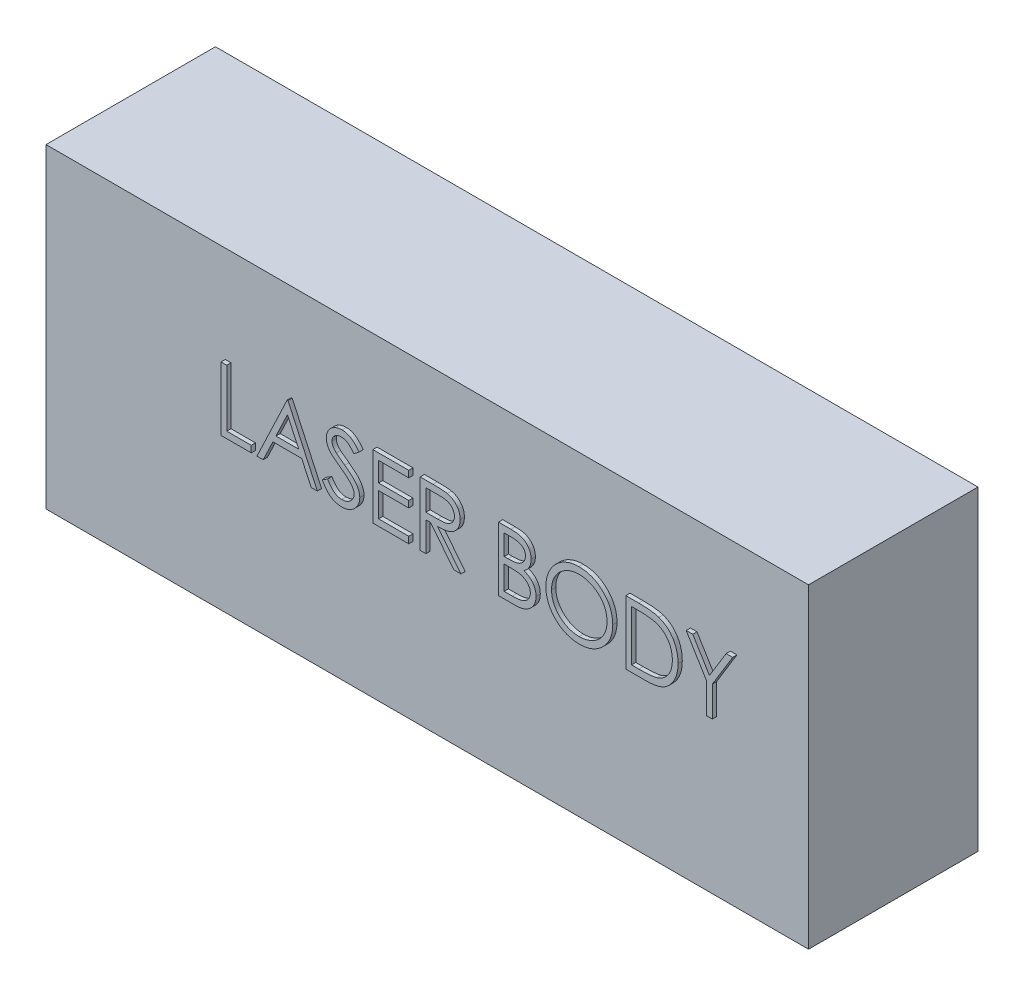
from build123d import *

# Parameters (mm, degrees)
SKETCH1_W                = 3600
SKETCH1_H                = 1490
BOSS_EXTRUDE1_DEPTH      = 800
BOSS_EXTRUDE2_DEPTH      = 20
BOSS_EXTRUDE2_DEPTH_BACK = 1


with BuildPart() as part:
    # Sketch1 → Boss-Extrude1 (new body)
    with BuildSketch(Plane.XY):
        with Locations((-1800, -745)):
            Rectangle(SKETCH1_W, SKETCH1_H)
    extrude(amount=BOSS_EXTRUDE1_DEPTH)

    # Sketch2 → Boss-Extrude2 (add, two sides)
    with BuildSketch(Plane.XY.offset(800)) as boss_extrude2_sk:
        Polygon((-2753.573068103, -455.44321141), (-2726.605119385, -455.44321141), (-2726.605119385, -725.122698589), (-2611.028196308, -725.122698589), (-2611.028196308, -755.94321141), (-2753.573068103, -755.94321141), align=None)
        Polygon((-2437.662811693, -455.44321141), (-2298.970504, -755.94321141), (-2328.286108968, -755.94321141), (-2372.710988776, -659.629108846), (-2508.93524759, -659.629108846), (-2554.624249994, -755.94321141), (-2584.06024759, -755.94321141), (-2441.515375795, -455.44321141), align=None)
        Polygon((-2439.890075314, -514.014225032), (-2494.307543263, -628.808596025), (-2386.917318904, -628.808596025), align=None, mode=Mode.SUBTRACT)
        with BuildLine():
            Line((-2275.855119385, -697.974160929), (-2250.452274834, -682.744493461))
            add(Edge.make_bspline(
                [(-2250.452274834, -682.744493461), (-2248.089637607, -686.69944994), (-2243.562915856, -694.27699393), (-2236.011663448, -704.516148544), (-2228.187252076, -713.218813717), (-2220.031739295, -720.33436245), (-2211.594905749, -725.936445441), (-2202.82167485, -729.90323705), (-2193.741611387, -732.377294364), (-2187.562144714, -732.677801795), (-2184.477114577, -732.827826794)],
                knots=[0, 0, 0, 0, 0.013814497, 0.026468043, 0.038101516, 0.04885528, 0.058856205, 0.068366651, 0.077638056, 0.086881278, 0.086881278, 0.086881278, 0.086881278], degree=3))
            add(Edge.make_bspline(
                [(-2184.477114577, -732.827826794), (-2181.84242841, -732.754447055), (-2176.619156896, -732.608971548), (-2168.929598607, -731.2111484), (-2161.461589584, -729.063678475), (-2154.369047973, -725.988195641), (-2147.749838783, -722.267277081), (-2141.945321083, -717.772983841), (-2136.927304795, -712.741222465), (-2132.822550815, -707.127654545), (-2129.673307786, -701.090425071), (-2127.25281734, -694.893604106), (-2125.909576016, -688.439845601), (-2125.707231898, -684.094575862), (-2125.605119385, -681.901745064)],
                knots=[0, 0, 0, 0, 0.007896967, 0.015655756, 0.023370519, 0.031164024, 0.038794723, 0.046091152, 0.053114543, 0.06004967, 0.066862499, 0.073492298, 0.079950159, 0.086529205, 0.086529205, 0.086529205, 0.086529205], degree=3))
            add(Edge.make_bspline(
                [(-2125.605119385, -681.901745064), (-2125.731699489, -679.399794967), (-2125.989018344, -674.313696028), (-2128.163906848, -666.809811538), (-2131.585249327, -659.383806598), (-2134.741584879, -654.790340796), (-2136.380259609, -652.405551153)],
                knots=[0, 0, 0, 0, 0.007493655, 0.015233506, 0.023259506, 0.031925476, 0.031925476, 0.031925476, 0.031925476], degree=3))
            add(Edge.make_bspline(
                [(-2136.380259609, -652.405551153), (-2137.72569377, -650.684388156), (-2140.550264494, -647.071021736), (-2145.406130932, -641.692480804), (-2151.104135889, -636.144527977), (-2157.44928396, -630.215314659), (-2164.672710588, -624.180605257), (-2172.548172896, -617.752628823), (-2181.276741359, -611.175836279), (-2187.398312426, -606.76513458), (-2190.556942302, -604.489285128)],
                knots=[0, 0, 0, 0, 0.006552556, 0.013756272, 0.021716082, 0.030406062, 0.039801702, 0.049945629, 0.060901524, 0.072581005, 0.072581005, 0.072581005, 0.072581005], degree=3))
            add(Edge.make_bspline(
                [(-2190.556942302, -604.489285128), (-2193.718545402, -602.237373534), (-2199.763289777, -597.931890047), (-2208.216662347, -591.542033662), (-2215.775908385, -585.699981434), (-2222.407429661, -580.350736967), (-2228.108309333, -575.49357476), (-2232.923470765, -571.175137414), (-2236.730252595, -567.278634545), (-2238.847110306, -564.750885061), (-2239.797527237, -563.615987852)],
                knots=[0, 0, 0, 0, 0.011644214, 0.022262851, 0.031787194, 0.040304706, 0.047819849, 0.0542541, 0.059703114, 0.064142974, 0.064142974, 0.064142974, 0.064142974], degree=3))
            add(Edge.make_bspline(
                [(-2239.797527237, -563.615987852), (-2241.125955764, -561.847241688), (-2243.738488745, -558.368764979), (-2247.187027214, -552.931873619), (-2250.118118191, -547.36633326), (-2252.415855565, -541.657188317), (-2254.350750925, -535.884589423), (-2255.652167548, -529.973218185), (-2256.467071769, -523.949599657), (-2256.550523756, -519.895983389), (-2256.592298872, -517.866789134)],
                knots=[0, 0, 0, 0, 0.006634169, 0.013046984, 0.019293494, 0.025475277, 0.031490693, 0.037536753, 0.043607037, 0.049691631, 0.049691631, 0.049691631, 0.049691631], degree=3))
            add(Edge.make_bspline(
                [(-2256.592298872, -517.866789134), (-2256.480237357, -514.687518489), (-2256.258509563, -508.396931874), (-2254.383345152, -499.207570575), (-2251.423600997, -490.434136754), (-2247.27713991, -482.16348953), (-2241.931901467, -474.610981742), (-2235.746239953, -467.689738074), (-2228.378710921, -461.871321229), (-2220.295035695, -456.787543073), (-2211.446910035, -452.808414352), (-2202.175119614, -449.806764484), (-2192.464928145, -448.105998216), (-2185.888001872, -447.861926543), (-2182.550832526, -447.738083205)],
                knots=[0, 0, 0, 0, 0.009530048, 0.018856398, 0.02801277, 0.037246578, 0.046498029, 0.055701965, 0.064990356, 0.07456157, 0.084286209, 0.094014388, 0.103732877, 0.113743581, 0.113743581, 0.113743581, 0.113743581], degree=3))
            add(Edge.make_bspline(
                [(-2182.550832526, -447.738083205), (-2179.009731915, -447.860219421), (-2171.967613, -448.103109372), (-2161.609016064, -450.214983133), (-2151.635788841, -453.709426525), (-2143.613017105, -457.675052731), (-2137.334047156, -461.63576428), (-2132.545559678, -465.243466336), (-2127.693132832, -469.396814946), (-2122.737625553, -474.106873074), (-2117.763006078, -479.416858418), (-2112.695421107, -485.290404708), (-2107.523020314, -491.691617576), (-2104.195552894, -496.261321141), (-2102.489734769, -498.603968621)],
                knots=[0, 0, 0, 0, 0.010615224, 0.021110292, 0.031561766, 0.042249282, 0.047877235, 0.053812604, 0.060217786, 0.067030349, 0.074312113, 0.082036264, 0.090299839, 0.09899232, 0.09899232, 0.09899232, 0.09899232], degree=3))
            Line((-2102.489734769, -498.603968621), (-2126.869241981, -517.084237051))
            add(Edge.make_bspline(
                [(-2126.869241981, -517.084237051), (-2128.341342755, -515.187765202), (-2131.176264655, -511.535603832), (-2135.48023917, -506.420980878), (-2139.536873084, -501.748937421), (-2143.533557408, -497.690888571), (-2147.259210624, -494.024605409), (-2150.875259537, -490.885689145), (-2154.329665979, -488.243384451), (-2158.684075021, -485.423530232), (-2164.154696266, -482.628321855), (-2171.02194002, -480.263036723), (-2178.198418777, -478.841666407), (-2183.086234281, -478.653734774), (-2185.560648231, -478.558596025)],
                knots=[0, 0, 0, 0, 0.007201452, 0.013868313, 0.020052147, 0.025756522, 0.030950177, 0.035729628, 0.040111986, 0.043985655, 0.051281339, 0.058477254, 0.065714092, 0.073133883, 0.073133883, 0.073133883, 0.073133883], degree=3))
            add(Edge.make_bspline(
                [(-2185.560648231, -478.558596025), (-2188.66494394, -478.662629121), (-2194.651285783, -478.863247146), (-2203.150304626, -481.054320169), (-2210.799654478, -484.50421989), (-2217.372238992, -489.339263009), (-2222.844513735, -495.06773681), (-2226.802996695, -501.659749938), (-2229.185546537, -508.93892479), (-2229.476282833, -514.016658427), (-2229.624350154, -516.602666538)],
                knots=[0, 0, 0, 0, 0.009293851, 0.017922316, 0.026137514, 0.034325098, 0.042246347, 0.049751599, 0.057214, 0.064958765, 0.064958765, 0.064958765, 0.064958765], degree=3))
            add(Edge.make_bspline(
                [(-2229.624350154, -516.602666538), (-2229.590597424, -518.21261491), (-2229.523036773, -521.435144236), (-2228.580772, -526.196044892), (-2227.370243899, -530.944918462), (-2225.451969373, -535.660414503), (-2222.803679734, -540.425001616), (-2219.32602106, -545.320725083), (-2214.94616384, -550.390736071), (-2211.591123208, -553.688283448), (-2209.819762814, -555.429289134)],
                knots=[0, 0, 0, 0, 0.004821721, 0.009651326, 0.014513833, 0.019510489, 0.024872018, 0.030834188, 0.03749398, 0.044943015, 0.044943015, 0.044943015, 0.044943015], degree=3))
            add(Edge.make_bspline(
                [(-2209.819762814, -555.429289134), (-2209.161979269, -556.016296636), (-2207.599236133, -557.410892094), (-2204.742260224, -559.694029333), (-2200.969457118, -562.51038164), (-2196.379345274, -565.995092668), (-2190.88729036, -570.037372487), (-2184.492688469, -574.585535474), (-2177.266819721, -579.787229884), (-2172.139266656, -583.423927299), (-2169.428036052, -585.346857243)],
                knots=[0, 0, 0, 0, 0.00264453, 0.006282799, 0.010966134, 0.016769071, 0.023571521, 0.03142293, 0.040309993, 0.050281709, 0.050281709, 0.050281709, 0.050281709], degree=3))
            add(Edge.make_bspline(
                [(-2169.428036052, -585.346857243), (-2166.166674066, -587.720065399), (-2159.851498597, -592.315454072), (-2150.865897808, -599.2197146), (-2142.71858657, -605.972187302), (-2135.380960092, -612.529750426), (-2128.780528381, -618.842662411), (-2122.990518363, -624.986872608), (-2117.951933522, -630.918362491), (-2112.527546337, -638.522950775), (-2106.984796404, -647.862583868), (-2102.224746981, -659.305472634), (-2099.223323149, -670.792842437), (-2098.830825896, -678.513703683), (-2098.637170667, -682.323119262)],
                knots=[0, 0, 0, 0, 0.012100058, 0.023430085, 0.033989178, 0.043837302, 0.052947851, 0.061379633, 0.069156382, 0.076273053, 0.0893848, 0.101637079, 0.113360688, 0.124778486, 0.124778486, 0.124778486, 0.124778486], degree=3))
            add(Edge.make_bspline(
                [(-2098.637170667, -682.323119262), (-2098.693590669, -685.017176037), (-2098.805335034, -690.352972824), (-2100.089836346, -698.187872996), (-2101.971796169, -705.797466236), (-2104.808278684, -713.087691748), (-2108.270309843, -720.191920658), (-2112.663297695, -726.923798965), (-2117.755286056, -733.432319758), (-2123.596470729, -739.543930944), (-2129.988183199, -745.154368628), (-2136.743740412, -750.145163763), (-2143.87419956, -754.306515529), (-2151.340879035, -757.702237825), (-2159.145493944, -760.358101258), (-2167.285419385, -762.282406165), (-2175.774073134, -763.463432202), (-2181.54371448, -763.586015722), (-2184.477114577, -763.648339615)],
                knots=[0, 0, 0, 0, 0.008074388, 0.015991977, 0.023759168, 0.03155151, 0.039412375, 0.047427305, 0.055615996, 0.064174252, 0.072747737, 0.081103541, 0.089331961, 0.097467376, 0.105671981, 0.114023664, 0.122528404, 0.131324484, 0.131324484, 0.131324484, 0.131324484], degree=3))
            add(Edge.make_bspline(
                [(-2184.477114577, -763.648339615), (-2186.746777596, -763.604451024), (-2191.257519566, -763.517226572), (-2197.929433653, -762.746119496), (-2204.46656124, -761.655123888), (-2210.786873169, -759.92303588), (-2216.971799511, -757.821512565), (-2222.994440647, -755.233921438), (-2228.857715414, -752.133001713), (-2234.594482171, -748.587528885), (-2240.190150589, -744.461428244), (-2245.592236336, -739.655703764), (-2250.977984978, -734.302896836), (-2256.188431433, -728.257647039), (-2261.328968537, -721.61762021), (-2266.298243413, -714.32069175), (-2271.199116603, -706.40660752), (-2274.27413034, -700.837476589), (-2275.855119385, -697.974160929)],
                knots=[0, 0, 0, 0, 0.006806444, 0.013527168, 0.020128209, 0.026669695, 0.033161136, 0.039713692, 0.046310615, 0.053042382, 0.059929009, 0.067137753, 0.074714363, 0.08269327, 0.091061424, 0.099894092, 0.109165497, 0.118976573, 0.118976573, 0.118976573, 0.118976573], degree=3))
        make_face()
        Polygon((-2036.996145026, -455.44321141), (-1867.483324513, -455.44321141), (-1867.483324513, -486.26372423), (-2010.028196308, -486.26372423), (-2010.028196308, -578.725262692), (-1867.483324513, -578.725262692), (-1867.483324513, -609.545775512), (-2010.028196308, -609.545775512), (-2010.028196308, -725.122698589), (-1867.483324513, -725.122698589), (-1867.483324513, -755.94321141), (-2036.996145026, -755.94321141), align=None)
        with BuildLine():
            Line((-1813.547427077, -455.44321141), (-1753.411309289, -455.44321141))
            add(Edge.make_bspline(
                [(-1753.411309289, -455.44321141), (-1749.398249541, -455.456569578), (-1741.692730285, -455.482218741), (-1730.653796644, -455.625236385), (-1720.623355887, -456.035148925), (-1711.60665254, -456.387900164), (-1703.60385202, -457.03113684), (-1696.590414629, -457.645929543), (-1690.598642315, -458.450725276), (-1686.971534224, -459.198148019), (-1685.329278039, -459.536560769)],
                knots=[0, 0, 0, 0, 0.012039413, 0.023117007, 0.033116121, 0.042155394, 0.050184102, 0.0571982, 0.063276538, 0.068305723, 0.068305723, 0.068305723, 0.068305723], degree=3))
            add(Edge.make_bspline(
                [(-1685.329278039, -459.536560769), (-1683.130766452, -460.079758767), (-1678.780643499, -461.154566874), (-1672.517359257, -463.426312602), (-1666.549058015, -466.055226088), (-1660.90053167, -469.142968361), (-1655.600073026, -472.712460159), (-1650.593029485, -476.702080385), (-1645.856680415, -481.089999052), (-1641.582571881, -485.986847586), (-1637.552519014, -491.124239346), (-1634.153552653, -496.679519041), (-1631.223550608, -502.488744475), (-1628.890767649, -508.610995628), (-1627.012387355, -514.986899184), (-1625.687934517, -521.674208731), (-1624.893653979, -528.642458164), (-1624.812788953, -533.395330047), (-1624.771786052, -535.805290737)],
                knots=[0, 0, 0, 0, 0.006789653, 0.013434465, 0.019955979, 0.026340762, 0.032718448, 0.039101812, 0.045532683, 0.052056419, 0.0585821, 0.065096943, 0.071557889, 0.078075235, 0.084723318, 0.091476046, 0.098502531, 0.105730101, 0.105730101, 0.105730101, 0.105730101], degree=3))
            add(Edge.make_bspline(
                [(-1624.771786052, -535.805290737), (-1624.897910032, -539.809247576), (-1625.144010585, -547.622004418), (-1627.438551629, -558.960374379), (-1631.197078537, -569.537056965), (-1636.37626378, -579.338734877), (-1642.97176448, -588.174348858), (-1650.898507259, -595.935015092), (-1660.160914188, -602.429241873), (-1668.783488314, -606.932689819), (-1676.400236031, -609.816880974), (-1682.6706676, -611.846231213), (-1689.510646668, -613.414151375), (-1696.854637825, -614.818785545), (-1704.733203104, -615.879266737), (-1713.127459343, -616.655981491), (-1722.043393218, -617.141421957), (-1728.168361887, -617.213714092), (-1731.319262013, -617.250903718)],
                knots=[0, 0, 0, 0, 0.012000826, 0.02341672, 0.034535943, 0.045576675, 0.05654447, 0.067484477, 0.07870879, 0.090366533, 0.096559737, 0.103127759, 0.11012142, 0.117594739, 0.125554549, 0.133958351, 0.142880411, 0.152332958, 0.152332958, 0.152332958, 0.152332958], degree=3))
            Line((-1731.319262013, -617.250903718), (-1620.919221949, -755.94321141))
            Line((-1620.919221949, -755.94321141), (-1654.267979962, -755.94321141))
            Line((-1654.267979962, -755.94321141), (-1764.668020026, -617.250903718))
            Line((-1764.668020026, -617.250903718), (-1786.579478359, -617.250903718))
            Line((-1786.579478359, -617.250903718), (-1786.579478359, -755.94321141))
            Line((-1786.579478359, -755.94321141), (-1813.547427077, -755.94321141))
            Line((-1813.547427077, -755.94321141), (-1813.547427077, -455.44321141))
        make_face()
        with BuildLine():
            Line((-1786.579478359, -486.26372423), (-1786.579478359, -586.430390897))
            Line((-1786.579478359, -586.430390897), (-1731.560047269, -586.851765096))
            add(Edge.make_bspline(
                [(-1731.560047269, -586.851765096), (-1728.991198213, -586.852901557), (-1724.012037095, -586.855104343), (-1716.808565731, -586.512210125), (-1710.101396141, -586.122133802), (-1703.916182991, -585.525482849), (-1698.250163167, -584.75654012), (-1693.106168689, -583.794683902), (-1688.475802662, -582.674071094), (-1683.075513863, -580.939617221), (-1677.045205956, -578.191671939), (-1670.491604901, -574.193691265), (-1664.910689903, -569.165114034), (-1660.195599153, -563.414964451), (-1656.406772251, -557.092766515), (-1653.735580157, -550.274303958), (-1652.040550469, -543.131711044), (-1651.84062821, -538.22256207), (-1651.739734769, -535.745094423)],
                knots=[0, 0, 0, 0, 0.007705363, 0.014935189, 0.021630253, 0.027859626, 0.033571936, 0.038778482, 0.043552623, 0.04785487, 0.05577612, 0.063375651, 0.070794221, 0.078193472, 0.085616193, 0.092803794, 0.100090532, 0.107514473, 0.107514473, 0.107514473, 0.107514473], degree=3))
            add(Edge.make_bspline(
                [(-1651.739734769, -535.745094423), (-1651.842945452, -533.328510021), (-1652.047471363, -528.539721529), (-1653.71728706, -521.528978374), (-1656.541075374, -514.912230227), (-1660.346456087, -508.71639373), (-1664.982669249, -503.092258409), (-1670.418955739, -498.280209982), (-1676.506673208, -494.309363086), (-1682.196528952, -491.771908416), (-1687.282209196, -490.216189588), (-1691.697812866, -489.121411095), (-1696.68709831, -488.241850262), (-1702.274291256, -487.537129607), (-1708.435539842, -486.931412251), (-1715.201997172, -486.523438112), (-1722.528769306, -486.281847779), (-1727.606955827, -486.269906006), (-1730.235728359, -486.26372423)],
                knots=[0, 0, 0, 0, 0.007243845, 0.014354658, 0.021476419, 0.028744485, 0.036097312, 0.043260926, 0.050440456, 0.057823774, 0.061860071, 0.066386017, 0.071463247, 0.077048219, 0.083277593, 0.090032735, 0.097380631, 0.105266578, 0.105266578, 0.105266578, 0.105266578], degree=3))
            Line((-1730.235728359, -486.26372423), (-1786.579478359, -486.26372423))
        make_face(mode=Mode.SUBTRACT)
        with BuildLine():
            Line((-1443.701273231, -455.44321141), (-1385.070063295, -455.44321141))
            add(Edge.make_bspline(
                [(-1385.070063295, -455.44321141), (-1382.199989668, -455.458300837), (-1376.63707268, -455.487547903), (-1368.547660603, -455.941142448), (-1360.970869861, -456.559628962), (-1353.904503121, -457.540984059), (-1347.351825673, -458.72510664), (-1341.293089961, -460.15907685), (-1335.747562314, -461.87850468), (-1329.126883088, -464.612735397), (-1321.578266347, -468.675767423), (-1313.404804345, -474.67963423), (-1306.415668937, -482.023207135), (-1300.389672271, -490.306932265), (-1295.598747573, -499.419446383), (-1292.132755046, -509.143556734), (-1289.93842889, -519.353837718), (-1289.712759038, -526.363487705), (-1289.598709128, -529.906051955)],
                knots=[0, 0, 0, 0, 0.008608915, 0.016686219, 0.024299804, 0.031408323, 0.038079259, 0.044269829, 0.050076512, 0.055475755, 0.065737594, 0.075718208, 0.085765043, 0.09602388, 0.106363637, 0.116531292, 0.126920346, 0.137535569, 0.137535569, 0.137535569, 0.137535569], degree=3))
            add(Edge.make_bspline(
                [(-1289.598709128, -529.906051955), (-1289.69256974, -533.224649949), (-1289.877014695, -539.746007968), (-1291.640757317, -549.284230779), (-1294.401980422, -558.363728281), (-1298.240245386, -566.951364515), (-1303.228716774, -574.853107587), (-1309.140695276, -582.1327), (-1316.273432176, -588.481926465), (-1321.617458923, -592.031509955), (-1324.331982366, -593.834537532)],
                knots=[0, 0, 0, 0, 0.009947156, 0.0195471, 0.028991593, 0.038367543, 0.047670747, 0.056950551, 0.066413825, 0.076183077, 0.076183077, 0.076183077, 0.076183077], degree=3))
            add(Edge.make_bspline(
                [(-1324.331982366, -593.834537532), (-1320.918265654, -595.145146726), (-1314.386979943, -597.652666778), (-1305.398938018, -602.085940187), (-1297.655066327, -606.907858522), (-1291.09582565, -612.173635941), (-1285.486121278, -617.849549554), (-1280.587718723, -624.018824363), (-1276.408075027, -630.761937718), (-1272.826722589, -638.008584111), (-1270.032179393, -645.684768037), (-1267.93933389, -653.718487527), (-1266.740128614, -662.080935052), (-1266.569475413, -667.772008335), (-1266.483324513, -670.645034327)],
                knots=[0, 0, 0, 0, 0.010965812, 0.020980315, 0.03001558, 0.038279155, 0.046153836, 0.053909822, 0.061860294, 0.069909737, 0.078117875, 0.086323142, 0.0947766, 0.10339498, 0.10339498, 0.10339498, 0.10339498], degree=3))
            add(Edge.make_bspline(
                [(-1266.483324513, -670.645034327), (-1266.567193722, -673.578504347), (-1266.732208739, -679.350188796), (-1267.949660603, -687.829022491), (-1270.011013932, -695.931785765), (-1272.85040807, -703.71088788), (-1276.556201081, -711.151279425), (-1281.066102018, -718.261389661), (-1286.443469124, -724.969780047), (-1292.458866872, -731.350993973), (-1299.264088221, -737.088636858), (-1306.606226607, -742.198485389), (-1314.577746358, -746.400854436), (-1323.047724702, -749.930958568), (-1332.111175271, -752.627490893), (-1341.727399131, -754.513993309), (-1351.88810276, -755.785111486), (-1358.860539963, -755.889617221), (-1362.436249193, -755.94321141)],
                knots=[0, 0, 0, 0, 0.008798757, 0.017311802, 0.025633711, 0.033841849, 0.04210652, 0.050523032, 0.059049899, 0.06786347, 0.076788982, 0.085705355, 0.094646281, 0.103768356, 0.113195376, 0.122958505, 0.133142896, 0.143863926, 0.143863926, 0.143863926, 0.143863926], degree=3))
            Line((-1362.436249193, -755.94321141), (-1443.701273231, -755.94321141))
            Line((-1443.701273231, -755.94321141), (-1443.701273231, -455.44321141))
        make_face()
        with BuildLine():
            Line((-1416.733324513, -486.26372423), (-1416.733324513, -582.577826794))
            Line((-1416.733324513, -582.577826794), (-1398.614233968, -582.577826794))
            add(Edge.make_bspline(
                [(-1398.614233968, -582.577826794), (-1395.965644537, -582.543490548), (-1390.848030007, -582.477145922), (-1383.436850317, -582.287099671), (-1376.557545183, -581.754953372), (-1370.221989229, -581.222960016), (-1364.440159397, -580.357984703), (-1359.224865003, -579.328375293), (-1354.494256894, -578.239457299), (-1349.038933056, -576.387562781), (-1342.850955624, -573.650636668), (-1336.254284825, -569.403126167), (-1330.438796793, -564.344049557), (-1325.528009676, -558.50653984), (-1321.508910563, -552.078743026), (-1318.717375876, -545.163218006), (-1316.824459049, -537.932318098), (-1316.653471856, -532.968208109), (-1316.566657846, -530.447818782)],
                knots=[0, 0, 0, 0, 0.007946825, 0.015354886, 0.022234143, 0.028643283, 0.034423697, 0.039759821, 0.044592427, 0.048970648, 0.057026391, 0.064824311, 0.072418119, 0.080063999, 0.087631755, 0.095054476, 0.102369009, 0.109913027, 0.109913027, 0.109913027, 0.109913027], degree=3))
            add(Edge.make_bspline(
                [(-1316.566657846, -530.447818782), (-1316.611834174, -528.779977542), (-1316.700452473, -525.508324823), (-1317.426228882, -520.739015987), (-1318.659787773, -516.253516664), (-1320.244220664, -511.990356621), (-1322.458363795, -508.082839195), (-1325.065284001, -504.395859107), (-1328.215012553, -501.054975791), (-1331.800176112, -497.932394578), (-1335.922059303, -495.163971549), (-1340.578203072, -492.73930031), (-1345.831602203, -490.786842198), (-1351.59372018, -489.07689825), (-1357.953252121, -487.875903309), (-1364.836810207, -486.87537674), (-1372.300776798, -486.366008462), (-1377.464663457, -486.29857945), (-1380.133965539, -486.26372423)],
                knots=[0, 0, 0, 0, 0.005002093, 0.009812151, 0.014426504, 0.018942832, 0.023415625, 0.027859157, 0.032459353, 0.037153894, 0.042095861, 0.047319083, 0.05286401, 0.058883642, 0.065329428, 0.072259067, 0.079743045, 0.087751191, 0.087751191, 0.087751191, 0.087751191], degree=3))
            Line((-1380.133965539, -486.26372423), (-1416.733324513, -486.26372423))
        make_face(mode=Mode.SUBTRACT)
        with BuildLine():
            Line((-1416.733324513, -613.398339615), (-1416.733324513, -725.122698589))
            Line((-1416.733324513, -725.122698589), (-1378.328076116, -725.122698589))
            add(Edge.make_bspline(
                [(-1378.328076116, -725.122698589), (-1375.579022619, -725.089751134), (-1370.280584419, -725.026249258), (-1362.630607375, -724.818942502), (-1355.540258035, -724.347391403), (-1349.041890953, -723.605083453), (-1343.065336377, -722.799876603), (-1337.682290731, -721.717108055), (-1332.849117978, -720.476561587), (-1327.244852414, -718.559013371), (-1320.934051203, -715.580073511), (-1314.13323339, -711.0885235), (-1308.086639518, -705.737622361), (-1302.951930835, -699.544668158), (-1298.743815676, -692.810778518), (-1295.682540175, -685.672156329), (-1293.794468048, -678.246756046), (-1293.565901799, -673.184042584), (-1293.451273231, -670.645034327)],
                knots=[0, 0, 0, 0, 0.008247774, 0.015896497, 0.02295591, 0.029556951, 0.035516082, 0.041041042, 0.046019899, 0.050474426, 0.058795029, 0.066875698, 0.074849153, 0.082926458, 0.09092804, 0.098587179, 0.106149906, 0.113758491, 0.113758491, 0.113758491, 0.113758491], degree=3))
            add(Edge.make_bspline(
                [(-1293.451273231, -670.645034327), (-1293.474978761, -669.057248948), (-1293.522007447, -665.907289312), (-1294.231240243, -661.278231122), (-1295.262716778, -656.794266856), (-1296.596201316, -652.443220852), (-1298.538244133, -648.303758111), (-1300.805434641, -644.294009785), (-1303.463692125, -640.408675337), (-1307.605798366, -635.49659472), (-1313.630564465, -629.837148326), (-1322.191103328, -624.296142774), (-1331.924924911, -619.827466766), (-1338.984742516, -617.930068869), (-1342.631661853, -616.949922147)],
                knots=[0, 0, 0, 0, 0.004758936, 0.009441111, 0.014011672, 0.018561574, 0.023060217, 0.027696896, 0.0323721, 0.03715837, 0.046954291, 0.057038566, 0.067625077, 0.0789375, 0.0789375, 0.0789375, 0.0789375], degree=3))
            add(Edge.make_bspline(
                [(-1342.631661853, -616.949922147), (-1344.093731368, -616.65327851), (-1347.263799654, -616.010093918), (-1352.433050488, -615.331161098), (-1358.334515804, -614.726292385), (-1364.981822834, -614.278877277), (-1372.383381764, -613.816404038), (-1380.555000068, -613.636548682), (-1389.463306656, -613.421969351), (-1395.644366057, -613.406417682), (-1398.855019225, -613.398339615)],
                knots=[0, 0, 0, 0, 0.004474413, 0.00970145, 0.015631321, 0.022270404, 0.029686532, 0.037876771, 0.046787655, 0.056419254, 0.056419254, 0.056419254, 0.056419254], degree=3))
            Line((-1398.855019225, -613.398339615), (-1416.733324513, -613.398339615))
        make_face(mode=Mode.SUBTRACT)
        with BuildLine():
            add(Edge.make_bspline(
                [(-1064.223709128, -447.738083205), (-1058.659470321, -447.879015934), (-1047.73084623, -448.155819441), (-1031.669130011, -450.27469676), (-1016.335465401, -453.940400956), (-1001.604943484, -458.822494166), (-987.653760782, -465.335134968), (-974.376907298, -473.206959847), (-961.805972845, -482.520438663), (-950.110394231, -493.203576569), (-939.407704642, -504.827213111), (-929.978367836, -517.231673675), (-922.075879474, -530.341956559), (-915.586299747, -544.118665019), (-910.495090543, -558.530642269), (-906.981898364, -573.654721647), (-904.737751472, -589.392910323), (-904.475391155, -600.127359709), (-904.342298872, -605.572818782)],
                knots=[0, 0, 0, 0, 0.016690018, 0.032780573, 0.048491234, 0.06392933, 0.079253992, 0.094584683, 0.110163787, 0.126101606, 0.14203556, 0.15750613, 0.172764441, 0.187870958, 0.203120598, 0.218524505, 0.234384492, 0.250713678, 0.250713678, 0.250713678, 0.250713678], degree=3))
            add(Edge.make_bspline(
                [(-904.342298872, -605.572818782), (-904.47537165, -610.978165247), (-904.737673512, -621.632729345), (-906.984449984, -637.271045051), (-910.508112982, -652.303831992), (-915.539020978, -666.705994466), (-921.997665629, -680.492725298), (-929.952773893, -693.627748052), (-939.323326415, -706.115368842), (-949.987371768, -717.818784814), (-961.612518376, -728.550710512), (-974.08157414, -737.902173981), (-987.114114894, -745.949059536), (-1000.877848408, -752.369772115), (-1015.190237285, -757.501618428), (-1030.179376738, -761.000522806), (-1045.775030878, -763.257453234), (-1056.410241347, -763.51661439), (-1061.815856564, -763.648339615)],
                knots=[0, 0, 0, 0, 0.016208913, 0.031949644, 0.047294982, 0.062467917, 0.077628906, 0.092887217, 0.108453988, 0.124391808, 0.140325762, 0.15584439, 0.171082502, 0.186189019, 0.20132513, 0.216611913, 0.232293024, 0.248501936, 0.248501936, 0.248501936, 0.248501936], degree=3))
            add(Edge.make_bspline(
                [(-1061.815856564, -763.648339615), (-1067.26128738, -763.515313687), (-1077.995681062, -763.253084171), (-1093.753646528, -761.005223558), (-1108.888349965, -757.490120189), (-1123.35651069, -752.466667165), (-1137.166196788, -745.974387784), (-1150.344416746, -738.057983239), (-1162.838274959, -728.664598689), (-1174.544187764, -718.004011357), (-1185.254797494, -706.398568106), (-1194.59256675, -693.963512777), (-1202.510751479, -680.942808571), (-1208.981231883, -667.300321143), (-1214.103851893, -653.102001563), (-1217.598651278, -638.253139424), (-1219.859780878, -622.838390425), (-1220.120344125, -612.34296444), (-1220.252555282, -607.01753032)],
                knots=[0, 0, 0, 0, 0.016329186, 0.032189173, 0.04765166, 0.062881447, 0.078042435, 0.093352312, 0.108919083, 0.124856903, 0.140790857, 0.156225197, 0.171432006, 0.186429709, 0.201452399, 0.216622109, 0.232124384, 0.248092754, 0.248092754, 0.248092754, 0.248092754], degree=3))
            add(Edge.make_bspline(
                [(-1220.252555282, -607.01753032), (-1220.206653005, -603.443068299), (-1220.115427529, -596.339237695), (-1219.017169362, -585.790262453), (-1217.423514729, -575.410935979), (-1215.139550523, -565.230773161), (-1212.152437401, -555.274694331), (-1208.62782762, -545.474035979), (-1204.322963755, -535.928119126), (-1199.456525259, -526.591722209), (-1194.02504717, -517.610386294), (-1188.025714967, -509.120867798), (-1181.66924976, -501.051927931), (-1174.700792679, -493.612663744), (-1167.350009313, -486.586659817), (-1159.497654276, -480.081889399), (-1151.191641581, -474.039697181), (-1142.396231547, -468.594607897), (-1133.328148232, -463.669916482), (-1123.980299168, -459.44386899), (-1114.4796421, -455.816742852), (-1104.781678757, -452.876923432), (-1094.912162183, -450.556030056), (-1084.849551822, -448.975627259), (-1074.601864222, -447.874567966), (-1067.697978124, -447.783773866), (-1064.223709128, -447.738083205)],
                knots=[0, 0, 0, 0, 0.01071917, 0.021303114, 0.03178367, 0.042210847, 0.05257196, 0.06295037, 0.073432482, 0.083960128, 0.094521279, 0.10489218, 0.115129978, 0.125310277, 0.135444018, 0.14561773, 0.155876566, 0.166232607, 0.176628983, 0.18681195, 0.196985662, 0.207116184, 0.217191292, 0.227374616, 0.237659029, 0.24807734, 0.24807734, 0.24807734, 0.24807734], degree=3))
        make_face()
        with BuildLine():
            add(Edge.make_bspline(
                [(-1062.899390218, -478.558596025), (-1065.751103756, -478.593358746), (-1071.427268255, -478.662551852), (-1079.865697724, -479.573986861), (-1088.193148043, -480.872995899), (-1096.411338995, -482.725923611), (-1104.485884697, -485.25047157), (-1112.492049632, -488.155955259), (-1120.356826114, -491.695080323), (-1128.054250196, -495.693679655), (-1135.516530219, -500.119522713), (-1142.557906444, -505.010955854), (-1149.196607733, -510.253268869), (-1155.416379627, -515.858696049), (-1161.198958838, -521.855783289), (-1166.658159634, -528.153613876), (-1171.575162287, -534.932197664), (-1176.081423954, -542.007719739), (-1180.113948527, -549.370964068), (-1183.699802554, -556.944410814), (-1186.633026738, -564.789837922), (-1189.025210759, -572.822130594), (-1191.008494519, -581.028567488), (-1192.264921431, -589.47140251), (-1193.186371149, -598.108211414), (-1193.251609309, -603.944939168), (-1193.284606564, -606.897137692)],
                knots=[0, 0, 0, 0, 0.008551267, 0.017020784, 0.025432775, 0.033829459, 0.042264894, 0.050797071, 0.059366117, 0.068116351, 0.076808832, 0.085374918, 0.093817223, 0.102170858, 0.110472058, 0.118796797, 0.127152601, 0.135569113, 0.143947653, 0.152322732, 0.160685688, 0.169046044, 0.177456311, 0.185987214, 0.194636442, 0.203488576, 0.203488576, 0.203488576, 0.203488576], degree=3))
            add(Edge.make_bspline(
                [(-1193.284606564, -606.897137692), (-1193.175150559, -611.238265507), (-1192.959816736, -619.77860689), (-1191.074602501, -632.293843244), (-1188.170744409, -644.321423257), (-1183.890133376, -655.795535755), (-1178.536887747, -666.814809181), (-1171.923579024, -677.281490741), (-1164.088334678, -687.19840924), (-1155.188080465, -696.496331618), (-1145.458516656, -704.982949954), (-1135.127092272, -712.432208324), (-1124.304489686, -718.735002631), (-1112.962486139, -723.869695274), (-1101.161633145, -727.938442762), (-1088.82588912, -730.726965235), (-1076.037428233, -732.56220076), (-1067.320296269, -732.738444518), (-1062.899390218, -732.827826794)],
                knots=[0, 0, 0, 0, 0.013016331, 0.025607149, 0.037885574, 0.050074399, 0.062269911, 0.074578548, 0.087138823, 0.100124635, 0.113137764, 0.125817628, 0.138279428, 0.15064446, 0.163113237, 0.175656335, 0.188536799, 0.201791065, 0.201791065, 0.201791065, 0.201791065], degree=3))
            add(Edge.make_bspline(
                [(-1062.899390218, -732.827826794), (-1059.927917294, -732.787001348), (-1054.034594028, -732.706032227), (-1045.26896418, -731.890502972), (-1036.661252288, -730.582738184), (-1028.223531686, -728.699834752), (-1019.965378595, -726.343296029), (-1011.852324784, -723.543689671), (-1003.970785858, -720.050917755), (-996.22133407, -716.191815055), (-988.803599605, -711.79248153), (-981.722486047, -707.067063252), (-975.156476919, -701.832471674), (-968.941358073, -696.310328054), (-963.135037918, -690.389289117), (-957.776780844, -684.077052927), (-952.884629498, -677.333776498), (-948.380078982, -670.268986663), (-944.361684565, -662.885594111), (-940.860507632, -655.284688904), (-937.890183973, -647.484987371), (-935.492322344, -639.475239591), (-933.613299134, -631.270658147), (-932.318580296, -622.860257436), (-931.412921492, -614.260862459), (-931.344658437, -608.44456854), (-931.31024759, -605.512622468)],
                knots=[0, 0, 0, 0, 0.008912308, 0.017675783, 0.026385131, 0.035016745, 0.043591287, 0.052139375, 0.060739236, 0.069434634, 0.078096422, 0.086594555, 0.09495231, 0.103265724, 0.111523816, 0.119809506, 0.128081189, 0.136497701, 0.144929054, 0.153278784, 0.161585439, 0.169945795, 0.17834248, 0.186813921, 0.195463149, 0.204255109, 0.204255109, 0.204255109, 0.204255109], degree=3))
            add(Edge.make_bspline(
                [(-931.31024759, -605.512622468), (-931.344686004, -602.600734173), (-931.413000943, -596.824467351), (-932.318147693, -588.28504566), (-933.614666994, -579.935162789), (-935.483150928, -571.807599132), (-937.891456984, -563.900282908), (-940.86102635, -556.220640713), (-944.362735634, -548.74006282), (-948.381556041, -541.477038178), (-952.899000314, -534.507607102), (-957.835291775, -527.844885684), (-963.275659523, -521.613997466), (-969.064665373, -515.661118734), (-975.346908527, -510.113211355), (-982.093931491, -504.968434939), (-989.223824396, -500.102629532), (-996.773005609, -495.713134865), (-1004.564022208, -491.659455742), (-1012.5585206, -488.186448187), (-1020.665933295, -485.235356222), (-1028.865643511, -482.718285366), (-1037.226667794, -480.880253063), (-1045.692510814, -479.572816211), (-1054.251459871, -478.662869079), (-1060.007599165, -478.593464008), (-1062.899390218, -478.558596025)],
                knots=[0, 0, 0, 0, 0.008731786, 0.017321106, 0.025733097, 0.034071101, 0.042316239, 0.050510458, 0.05875098, 0.067076807, 0.075391964, 0.083650933, 0.091930061, 0.100188152, 0.108546557, 0.117046823, 0.125628546, 0.134424626, 0.143228324, 0.1519626, 0.160551287, 0.169101919, 0.17767477, 0.186205673, 0.194794993, 0.203466606, 0.203466606, 0.203466606, 0.203466606], degree=3))
        make_face(mode=Mode.SUBTRACT)
        with BuildLine():
            Line((-842.701273231, -755.94321141), (-842.701273231, -455.44321141))
            Line((-842.701273231, -455.44321141), (-782.023388616, -455.44321141))
            add(Edge.make_bspline(
                [(-782.023388616, -455.44321141), (-776.745836914, -455.481209205), (-766.549634492, -455.554620748), (-751.815480075, -456.020085902), (-738.182759897, -456.843495898), (-725.696310139, -458.042879499), (-714.321851796, -459.515589957), (-704.091234156, -461.361553245), (-694.951557316, -463.541309016), (-689.330538202, -465.39972553), (-686.672427077, -466.278547948)],
                knots=[0, 0, 0, 0, 0.015832661, 0.030588618, 0.044219063, 0.056797644, 0.068214173, 0.078616298, 0.087974841, 0.096370662, 0.096370662, 0.096370662, 0.096370662], degree=3))
            add(Edge.make_bspline(
                [(-686.672427077, -466.278547948), (-683.195664459, -467.603384247), (-676.320980665, -470.223013953), (-666.532654856, -475.164633539), (-657.318005835, -480.763644132), (-648.627619254, -487.027426058), (-640.660005444, -494.133336549), (-633.103898882, -501.779523472), (-626.268406167, -510.244036682), (-620.008708179, -519.351332079), (-614.364832275, -528.99412399), (-609.459027435, -539.154038323), (-605.38476315, -549.779478615), (-602.002573267, -560.840896321), (-599.337013127, -572.362613901), (-597.518392991, -584.358047259), (-596.318883718, -596.779789091), (-596.198335883, -605.208768049), (-596.137170667, -609.485579198)],
                knots=[0, 0, 0, 0, 0.011155824, 0.022058671, 0.03283667, 0.043480529, 0.054143605, 0.064828239, 0.0756963, 0.086733257, 0.097955794, 0.109182851, 0.120540668, 0.132060834, 0.143859465, 0.155983009, 0.168436083, 0.181262983, 0.181262983, 0.181262983, 0.181262983], degree=3))
            add(Edge.make_bspline(
                [(-596.137170667, -609.485579198), (-596.191172018, -613.199865531), (-596.297587319, -620.519254697), (-597.253118582, -631.30642302), (-598.641971203, -641.773573931), (-600.792194475, -651.87086332), (-603.402467414, -661.686757456), (-606.747818118, -671.116640149), (-610.58009429, -680.247015779), (-615.048948149, -688.954430496), (-619.954944204, -697.203874321), (-625.21985387, -704.980430378), (-630.838061575, -712.173131565), (-636.863140915, -718.803759541), (-643.217231998, -724.862318486), (-649.941935237, -730.399418661), (-657.054602882, -735.306717156), (-664.523377793, -739.777050304), (-672.5661426, -743.676712256), (-681.335236255, -746.976203098), (-690.868055964, -749.710462504), (-701.141202837, -751.9917637), (-712.17242714, -753.801400684), (-723.972544063, -755.014252378), (-736.523423649, -755.834439885), (-745.141700565, -755.906250229), (-749.577575314, -755.94321141)],
                knots=[0, 0, 0, 0, 0.011140385, 0.021953292, 0.032466988, 0.042797103, 0.052902198, 0.062916158, 0.072788537, 0.082587972, 0.092250934, 0.101567371, 0.110743311, 0.119607104, 0.128420674, 0.13706089, 0.145710747, 0.154320714, 0.16315133, 0.172486612, 0.182392519, 0.192878433, 0.204041401, 0.215907406, 0.228452671, 0.241758235, 0.241758235, 0.241758235, 0.241758235], degree=3))
            Line((-749.577575314, -755.94321141), (-842.701273231, -755.94321141))
        make_face()
        with BuildLine():
            Line((-815.733324513, -725.122698589), (-781.240836532, -725.122698589))
            add(Edge.make_bspline(
                [(-781.240836532, -725.122698589), (-776.284443559, -725.101397744), (-766.751484724, -725.060428416), (-753.043705242, -724.700927119), (-740.518917059, -724.113497913), (-729.175341753, -723.29140909), (-719.019384095, -722.203717986), (-710.029819284, -720.990994193), (-702.236114962, -719.480127349), (-697.520030448, -718.110623548), (-695.340696308, -717.477766698)],
                knots=[0, 0, 0, 0, 0.014868977, 0.028598488, 0.041133783, 0.052482026, 0.062712743, 0.071770639, 0.079692117, 0.086497496, 0.086497496, 0.086497496, 0.086497496], degree=3))
            add(Edge.make_bspline(
                [(-695.340696308, -717.477766698), (-692.597701221, -716.511740055), (-687.177227428, -714.602760295), (-679.374437113, -711.120595384), (-672.097442856, -706.995840538), (-665.219424971, -702.410873872), (-658.837950697, -697.203981413), (-652.877394426, -691.488386517), (-647.349756909, -685.235000829), (-642.312148466, -678.451585815), (-637.803935505, -671.180361932), (-633.899905666, -663.492813498), (-630.478367025, -655.473171649), (-627.79287643, -646.998285313), (-625.688038418, -638.143919012), (-624.197155923, -628.909449845), (-623.26863458, -619.29660236), (-623.160330264, -612.758398548), (-623.105119385, -609.425382884)],
                knots=[0, 0, 0, 0, 0.008722444, 0.017236552, 0.025591705, 0.033789241, 0.042005983, 0.050265391, 0.058538826, 0.067014544, 0.075584013, 0.084172068, 0.092858919, 0.101711053, 0.110807272, 0.120139448, 0.129753159, 0.139750279, 0.139750279, 0.139750279, 0.139750279], degree=3))
            add(Edge.make_bspline(
                [(-623.105119385, -609.425382884), (-623.149188771, -605.910951219), (-623.235763471, -599.006819104), (-624.323943552, -588.876475124), (-625.914151388, -579.1333507), (-628.213722147, -569.77679421), (-631.144101888, -560.788551402), (-634.80115613, -552.218333455), (-638.979533013, -543.975629713), (-643.950948076, -536.250687741), (-649.395629735, -528.944836514), (-655.438073375, -522.25185019), (-661.982279825, -516.156482409), (-668.9568719, -510.563807137), (-676.558414278, -505.698825821), (-684.607838302, -501.347012203), (-693.223230928, -497.653790675), (-699.217149528, -495.689476886), (-702.26327243, -494.691208205)],
                knots=[0, 0, 0, 0, 0.010538654, 0.020703279, 0.030530223, 0.040136959, 0.049578766, 0.058858375, 0.068065853, 0.077267229, 0.086380959, 0.095374418, 0.104275537, 0.113187845, 0.122154065, 0.131311031, 0.140614234, 0.150227757, 0.150227757, 0.150227757, 0.150227757], degree=3))
            add(Edge.make_bspline(
                [(-702.26327243, -494.691208205), (-704.783277997, -493.994354897), (-710.141501248, -492.51265357), (-718.885146659, -490.896360872), (-728.725675918, -489.470746028), (-739.706778827, -488.263762936), (-751.815937958, -487.397694346), (-765.062466313, -486.747642906), (-779.452089505, -486.309202032), (-789.427189911, -486.279263027), (-794.604418263, -486.26372423)],
                knots=[0, 0, 0, 0, 0.007840555, 0.016671172, 0.026648518, 0.037670199, 0.049803303, 0.063063036, 0.077456124, 0.09298724, 0.09298724, 0.09298724, 0.09298724], degree=3))
            Line((-794.604418263, -486.26372423), (-815.733324513, -486.26372423))
            Line((-815.733324513, -486.26372423), (-815.733324513, -725.122698589))
        make_face(mode=Mode.SUBTRACT)
        Polygon((-557.611529641, -455.44321141), (-526.730820507, -455.44321141), (-447.753256404, -584.56430516), (-368.89608493, -455.44321141), (-338.015375795, -455.44321141), (-434.329478359, -613.097358044), (-434.329478359, -755.94321141), (-461.297427077, -755.94321141), (-461.297427077, -613.097358044), align=None)
    extrude(amount=BOSS_EXTRUDE2_DEPTH)
    extrude(boss_extrude2_sk.sketch, amount=-BOSS_EXTRUDE2_DEPTH_BACK)


solid = part.part
